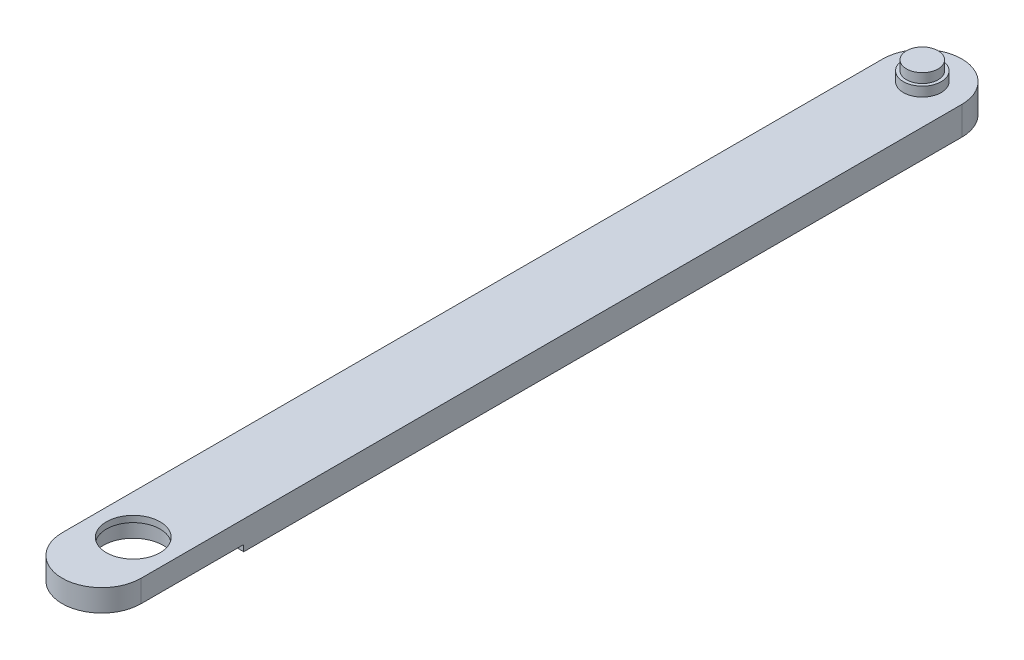
from build123d import *

# Parameters (mm, degrees)
EXTRUDE_1_DEPTH      = 10.5
EXTRUDE_1_DEPTH_BACK = 10.5
SKETCH_1_R           = 5
EXTRUDE_3_DEPTH      = 4.5
EXTRUDE_3_DEPTH_BACK = 4.5
SKETCH_7_R           = 6
EXTRUDE_4_DEPTH      = 3
EXTRUDE_START        = 3
SKETCH_8_R           = 6
EXTRUDE_5_DEPTH      = 3
SKETCH_9_R           = 9.5
CUT_EXTRUDE_1_DEPTH  = 7
SKETCH_10_R          = 8.5
CUT_EXTRUDE_2_DEPTH  = 274.096136919
SKETCH_13_W          = 25
SKETCH_13_H          = 45
CUT_EXTRUDE_3_DEPTH  = 2


with BuildPart() as part:
    # 스케치1 → 보스-돌출1 (new, two sides: drawn at the far end of the back side and taken through both)
    with BuildSketch(Plane(origin=(0, 0, 0), x_dir=(1, 0, 0), z_dir=(0, 1, 0)).offset(-EXTRUDE_1_DEPTH_BACK)):
        Circle(SKETCH_1_R)
    extrude(amount=EXTRUDE_1_DEPTH + EXTRUDE_1_DEPTH_BACK)

    # 스케치6 → 보스-돌출3 (add, two sides: drawn at the far end of the back side and taken through both)
    with BuildSketch(Plane(origin=(0, 0, 0), x_dir=(1, 0, 0), z_dir=(0, 1, 0)).offset(-EXTRUDE_3_DEPTH_BACK)):
        with BuildLine():
            Line((-12.5, 0), (-12.5, -260))
            ThreePointArc((-12.5, -260), (0, -272.5), (12.5, -260))
            Line((12.5, -260), (12.5, 0))
            ThreePointArc((12.5, 0), (0, 12.5), (-12.5, 0))
        make_face()
    extrude(amount=EXTRUDE_3_DEPTH + EXTRUDE_3_DEPTH_BACK)

    # 스케치7 → 보스-돌출4 (add)
    with BuildSketch(Plane.XZ.offset(4.5)):
        Circle(SKETCH_7_R)
    extrude(amount=EXTRUDE_4_DEPTH)

    # 스케치8 → 보스-돌출5 (add)
    with BuildSketch(Plane(origin=(0, 4.5, 0), x_dir=(1, 0, 0), z_dir=(0, 1, 0)).offset(EXTRUDE_START)):
        Circle(SKETCH_8_R)
    extrude(amount=-EXTRUDE_5_DEPTH)

    # 스케치9 → 컷-돌출1 (cut)
    with BuildSketch(Plane.XZ.offset(4.5)):
        with Locations((0, 250)):
            Circle(SKETCH_9_R)
    extrude(amount=-CUT_EXTRUDE_1_DEPTH, mode=Mode.SUBTRACT)

    # 스케치10 → 컷-돌출2 (cut, through all)
    with BuildSketch(Plane.XZ.offset(-2.5)):
        with Locations((0, 250)):
            Circle(SKETCH_10_R)
    extrude(amount=-CUT_EXTRUDE_2_DEPTH, mode=Mode.SUBTRACT)

    # 스케치13 → 컷-돌출3 (cut)
    with BuildSketch(Plane.XZ.offset(4.5)):
        with Locations((0, 250)):
            Rectangle(SKETCH_13_W, SKETCH_13_H)
    extrude(amount=-CUT_EXTRUDE_3_DEPTH, mode=Mode.SUBTRACT)


solid = part.part
